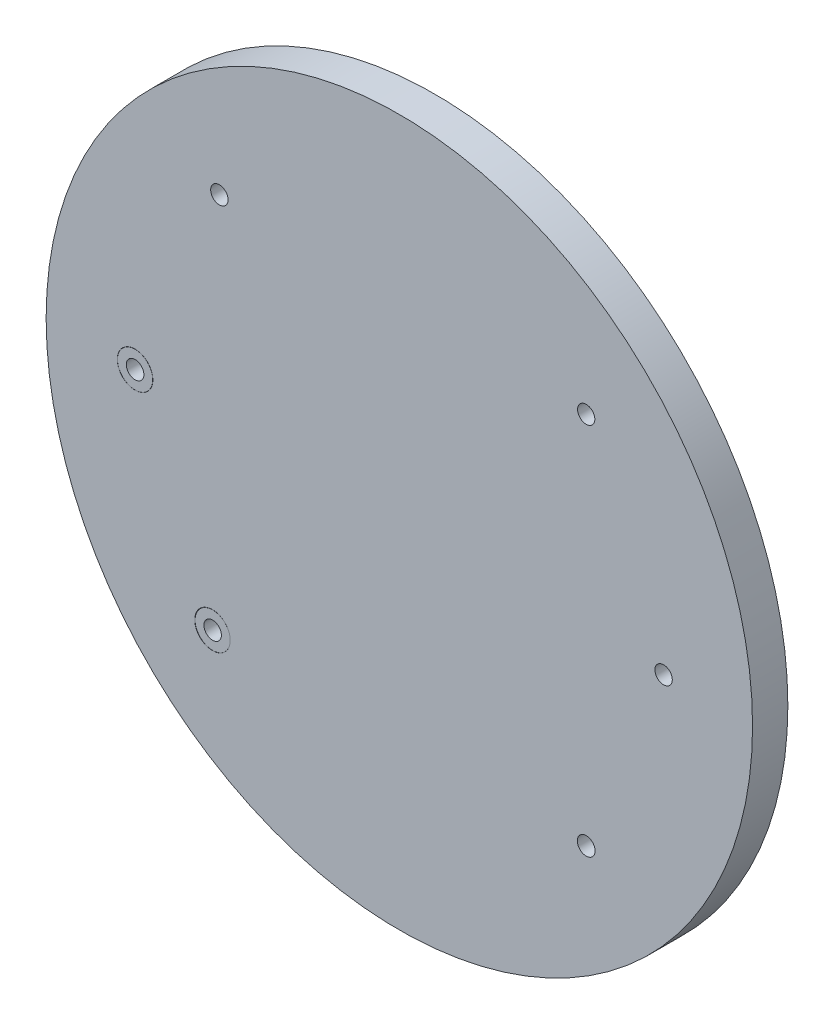
from build123d import *

# Parameters (mm, degrees)
SKETCH1_R           = 100.040239399
SKETCH1_R_2         = 4.999787409
SKETCH1_R_3         = 4.994100705
SKETCH1_R_4         = 4.985498273
SKETCH1_R_5         = 5.024681181
SKETCH1_R_6         = 5.034429614
SKETCH1_R_7         = 5.005688948
BOSS_EXTRUDE1_DEPTH = 10
SKETCH2_R           = 4.994100705
SKETCH2_R_2         = 2.462950525
BOSS_EXTRUDE2_DEPTH = 10
SKETCH3_R           = 4.990024035
SKETCH3_R_2         = 2.495309741
SKETCH3_R_3         = 4.999787409
SKETCH3_R_4         = 2.519899569
SKETCH3_R_5         = 4.976252145
SKETCH3_R_6         = 2.472796097
SKETCH3_R_7         = 5.005688948
SKETCH3_R_8         = 2.472512655
SKETCH3_R_9         = 4.985498273
SKETCH3_R_10        = 2.447326027
BOSS_EXTRUDE4_DEPTH = 10


with BuildPart() as part:
    # Sketch1 → Boss-Extrude1 (new body)
    with BuildSketch(Plane.XY):
        Circle(SKETCH1_R)
        with Locations((52.924174166, -52.924174166)):
            Circle(SKETCH1_R_2, mode=Mode.SUBTRACT)
        with Locations((74.846084883, 0)):
            Circle(SKETCH1_R_3, mode=Mode.SUBTRACT)
        with Locations((52.924174166, 52.924174166)):
            Circle(SKETCH1_R_4, mode=Mode.SUBTRACT)
        with Locations((-52.924174166, -52.924174166)):
            Circle(SKETCH1_R_5, mode=Mode.SUBTRACT)
        with Locations((-74.846084883, 0)):
            Circle(SKETCH1_R_6, mode=Mode.SUBTRACT)
        with Locations((-50.96624125, 54.812212828)):
            Circle(SKETCH1_R_7, mode=Mode.SUBTRACT)
    extrude(amount=BOSS_EXTRUDE1_DEPTH)

    # Sketch2 → Boss-Extrude2 (add)
    with BuildSketch(Plane(origin=(0, 0, 0), x_dir=(-1, 0, 0), z_dir=(0, 0, -1))):
        with Locations((-74.846084883, 0)):
            Circle(SKETCH2_R)
        with Locations((-74.846084883, 0)):
            Circle(SKETCH2_R_2, mode=Mode.SUBTRACT)
    extrude(amount=-BOSS_EXTRUDE2_DEPTH)

    # Sketch3 → Boss-Extrude4 (add)
    with BuildSketch(Plane(origin=(0, 0, 0), x_dir=(-1, 0, 0), z_dir=(0, 0, -1))):
        with Locations((74.846084883, 0)):
            Circle(SKETCH3_R)
        with Locations((74.846084883, 0)):
            Circle(SKETCH3_R_2, mode=Mode.SUBTRACT)
        with Locations((-52.924174166, -52.924174166)):
            Circle(SKETCH3_R_3)
        with Locations((-52.924174166, -52.924174166)):
            Circle(SKETCH3_R_4, mode=Mode.SUBTRACT)
        with Locations((52.875745129, -52.924174166)):
            Circle(SKETCH3_R_5)
        with Locations((52.875745129, -52.924174166)):
            Circle(SKETCH3_R_6, mode=Mode.SUBTRACT)
        with Locations((50.96624125, 54.812212828)):
            Circle(SKETCH3_R_7)
        with Locations((50.96624125, 54.812212828)):
            Circle(SKETCH3_R_8, mode=Mode.SUBTRACT)
        with Locations((-52.924174166, 52.924174166)):
            Circle(SKETCH3_R_9)
        with Locations((-52.924174166, 52.924174166)):
            Circle(SKETCH3_R_10, mode=Mode.SUBTRACT)
    extrude(amount=-BOSS_EXTRUDE4_DEPTH)


solid = part.part
